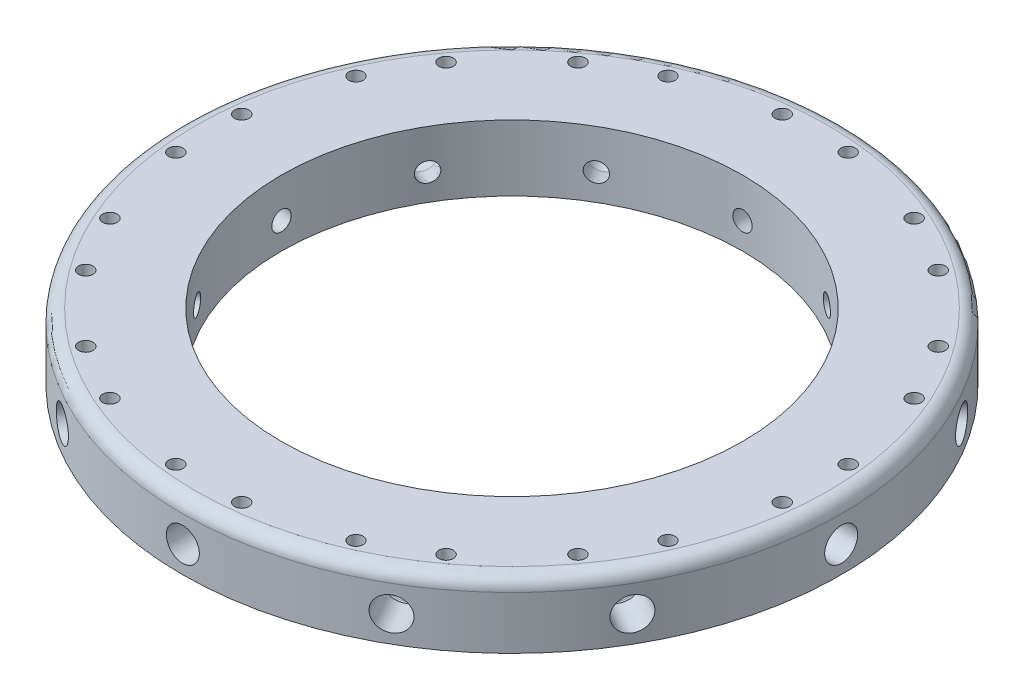
from build123d import *

# Parameters (mm, degrees)
HOLEWZD1_D           = 10
HOLEWZD1_CBORE_D     = 11
HOLEWZD1_CBORE_DEPTH = 20
CIRPATTERN1_COUNT    = 12


with BuildPart() as part:
    # Sketch1 → Revolve1 (revolve)
    with BuildSketch(Plane.XY, mode=Mode.PRIVATE) as revolve1_sk:
        with BuildLine():
            Line((175, 50), (240, 50))
            ThreePointArc((240, 50), (247.071067812, 47.071067812), (250, 40))
            Line((250, 40), (250, 0))
            Line((250, 0), (175, 0))
            Line((175, 0), (175, 50))
        make_face()
    revolve(revolve1_sk.sketch.rotate(Axis((0, 77.702702703, 0), (0, -1, 0)), 90), axis=Axis((0, 77.702702703, 0), (0, -1, 0)))  # turned: the seam where the file's is

    # HoleWzd1 (through all)
    with Locations(Plane(origin=(0, 50, 0), x_dir=(1, 0, 0), z_dir=(0, 1, 0))):
        with Locations((-25, -230), (25, -230)):
            holewzd1 = CounterBoreHole(HOLEWZD1_D / 2, HOLEWZD1_CBORE_D / 2, HOLEWZD1_CBORE_DEPTH)

    # Sketch4 → Cut-Revolve1 (revolve, cut)
    with BuildSketch(Plane(origin=(0, 0, 0), x_dir=(0, 0, -1), z_dir=(1, 0, 0)), mode=Mode.PRIVATE) as cut_revolve1_sk:
        with BuildLine():
            Line((-133.287181804, 20), (-266.892742396, 20))
            Line((-266.892742396, 20), (-266.892742396, 32.5))
            Line((-266.892742396, 32.5), (-221.443375673, 32.5))
            Line((-221.443375673, 32.5), (-220.866025404, 31.5))
            ThreePointArc((-220.866025404, 31.5), (-219.767949192, 30.401923789), (-218.267949192, 30))
            Line((-218.267949192, 30), (-190, 30))
            Line((-190, 30), (-133.287181804, 20))
        make_face()
    cut_revolve1 = revolve(cut_revolve1_sk.sketch.rotate(Axis((0, 20, 145.42409506), (0, 0, -1)), 180), axis=Axis((0, 20, 145.42409506), (0, 0, -1)), mode=Mode.SUBTRACT)  # turned: the seam where the file's is

    # CirPattern1: HoleWzd1, Cut-Revolve1 ×12 about axis
    cirpattern1_axis = Axis((0, 0, 0), (0, 1, 0))
    add([holewzd1.rotate(cirpattern1_axis, i * 360 / CIRPATTERN1_COUNT) for i in range(1, CIRPATTERN1_COUNT)], mode=Mode.SUBTRACT)
    add([cut_revolve1.rotate(cirpattern1_axis, i * 360 / CIRPATTERN1_COUNT) for i in range(1, CIRPATTERN1_COUNT)], mode=Mode.SUBTRACT)


solid = part.part
